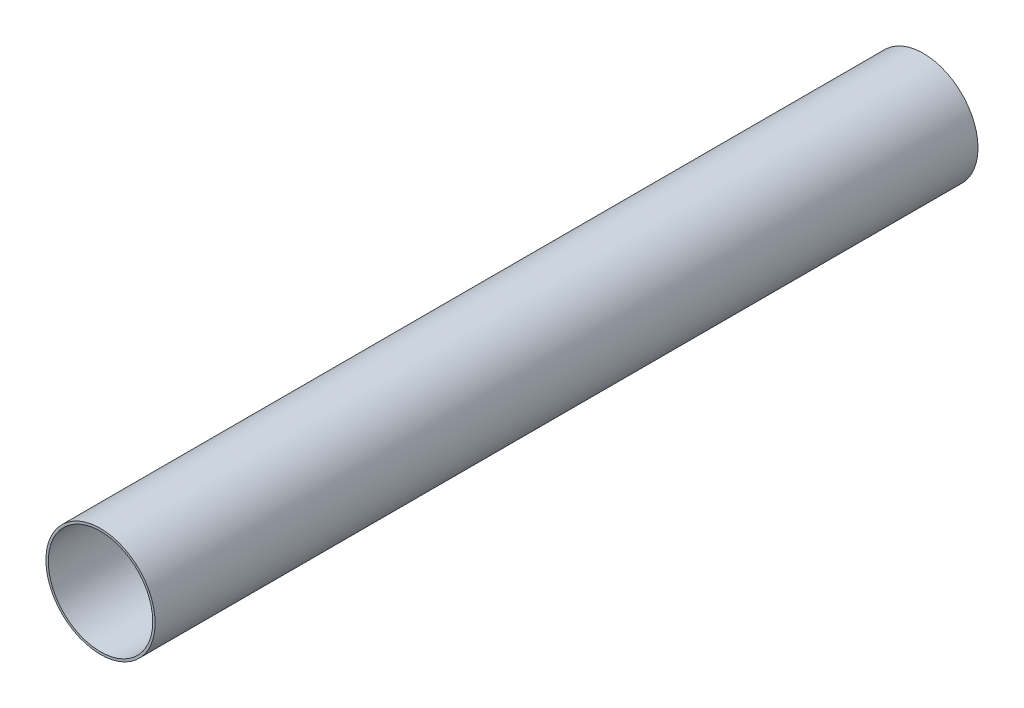
from build123d import *

# Parameters (mm, degrees)
SKETCH1_R           = 26.545
SKETCH1_R_2         = 25.4
BOSS_EXTRUDE1_DEPTH = 400


with BuildPart() as part:
    # Sketch1 → Boss-Extrude1 (new body)
    with BuildSketch(Plane.XY):
        Circle(SKETCH1_R)
        Circle(SKETCH1_R_2, mode=Mode.SUBTRACT)
    extrude(amount=BOSS_EXTRUDE1_DEPTH)


solid = part.part
